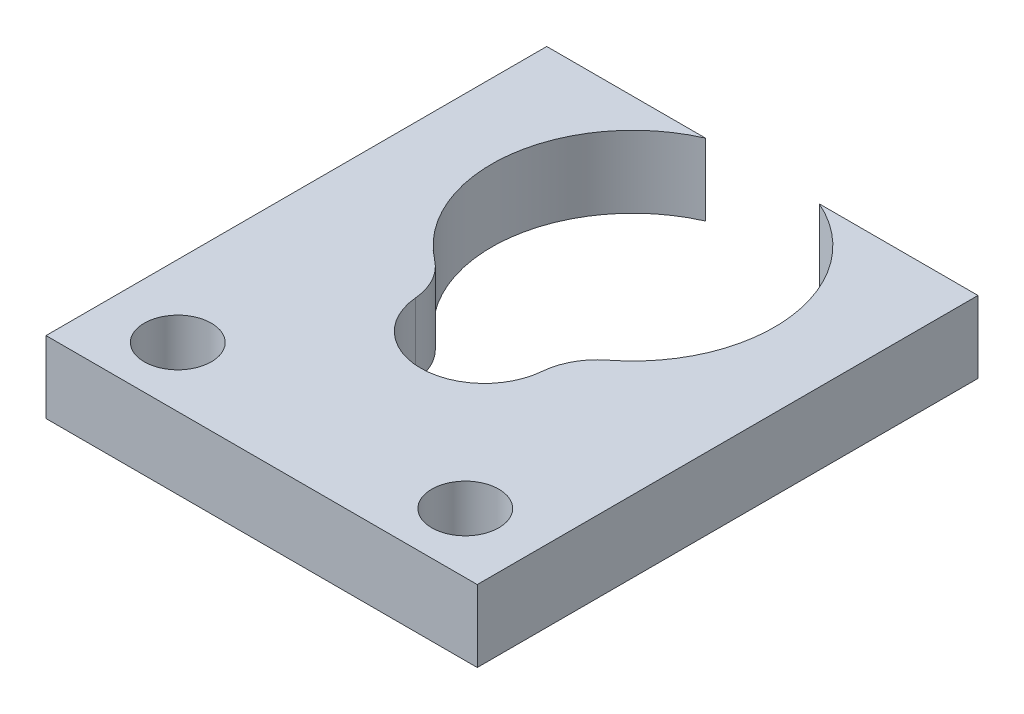
from build123d import *

# Parameters (mm, degrees)
CROQUIS1_R              = 1.4
SALIENTE_EXTRUIR1_DEPTH = 3


with BuildPart() as part:
    # Croquis1 → Saliente-Extruir1 (new body)
    with BuildSketch(Plane(origin=(0, 0, 0), x_dir=(1, 0, 0), z_dir=(0, 1, 0))):
        with BuildLine():
            Line((2.376972865, 5.4), (9, 5.4))
            Line((9, 5.4), (9, -15.5))
            Line((9, -15.5), (-9, -15.5))
            Line((-9, -15.5), (-9, 5.4))
            Line((-9, 5.4), (-2.376972865, 5.4))
            ThreePointArc((-2.376972865, 5.4), (-5.856174249, 0.717790472), (-3.610771276, -4.666083025))
            ThreePointArc((-3.610771276, -4.666083025), (-2.945738566, -5.446622945), (-2.65, -6.428483309))
            ThreePointArc((-2.65, -6.428483309), (0, -8.859831691), (2.65, -6.428483309))
            ThreePointArc((2.65, -6.428483309), (2.945738566, -5.446622945), (3.610771276, -4.666083025))
            ThreePointArc((3.610771276, -4.666083025), (5.856174249, 0.717790472), (2.376972865, 5.4))
        make_face()
        with Locations((-6, -13)):
            Circle(CROQUIS1_R, mode=Mode.SUBTRACT)
        with Locations((6, -13)):
            Circle(CROQUIS1_R, mode=Mode.SUBTRACT)
    extrude(amount=SALIENTE_EXTRUIR1_DEPTH)


solid = part.part
